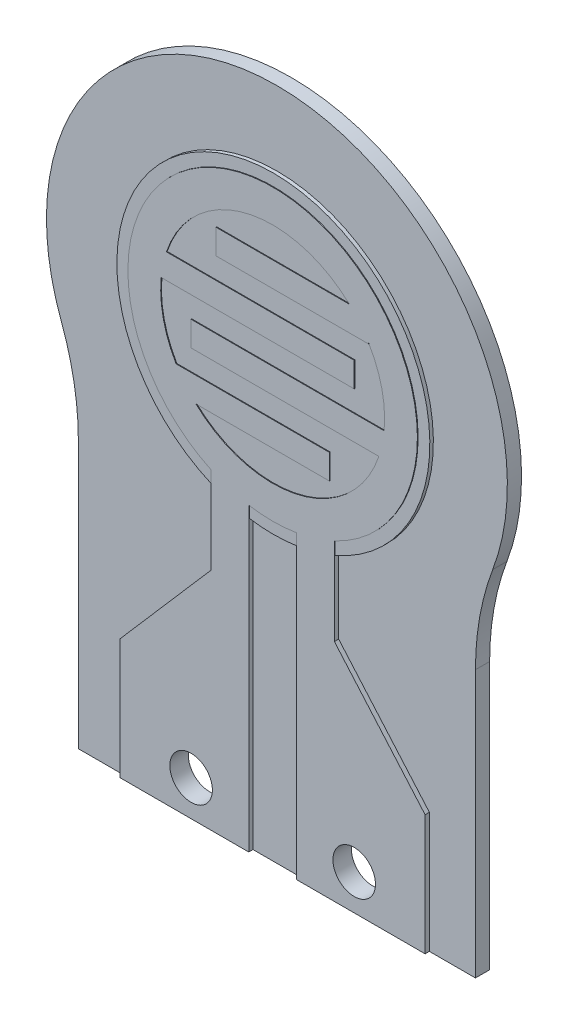
from build123d import *

# Parameters (mm, degrees)
BOSS_EXTRUDE1_DEPTH = 0.2
SKETCH2_R           = 2.206807536
BOSS_EXTRUDE2_DEPTH = 0.25
BOSS_EXTRUDE3_DEPTH = 0.06
SKETCH5_R           = 0.3
CUT_EXTRUDE1_DEPTH  = 1.26


with BuildPart() as part:
    # Sketch1 → Boss-Extrude1 (new body)
    with BuildSketch(Plane.XY):
        with BuildLine():
            Line((-2.8, -6.25), (2.8, -6.25))
            Line((2.8, -6.25), (2.8, -2.484625193))
            ThreePointArc((2.8, -2.484625193), (2.861380635, -1.801298833), (3.043557337, -1.139850312))
            ThreePointArc((3.043557337, -1.139850312), (0, 3.25), (-3.043557337, -1.139850312))
            ThreePointArc((-3.043557337, -1.139850312), (-2.861380635, -1.801298833), (-2.8, -2.484625193))
            Line((-2.8, -2.484625193), (-2.8, -6.25))
        make_face()
    extrude(amount=BOSS_EXTRUDE1_DEPTH)

    # Sketch2 → Boss-Extrude2 (add)
    with BuildSketch(Plane(origin=(0, 0, 0), x_dir=(-1, 0, 0), z_dir=(0, 0, -1))):
        Circle(SKETCH2_R)
    extrude(amount=-BOSS_EXTRUDE2_DEPTH)

    # Sketch3 → Boss-Extrude3 (add)
    with BuildSketch(Plane.XY.offset(0.2)):
        with BuildLine():
            Line((0.870696458, -1.846445486), (0.870696458, -3.07534158))
            Line((0.870696458, -3.07534158), (2.15, -4.550780247))
            Line((2.15, -4.550780247), (2.15, -6.25))
            Line((2.15, -6.25), (0.337052097, -6.25))
            Line((0.337052097, -6.25), (0.337052097, -2.013422245))
            ThreePointArc((0.337052097, -2.013422245), (0, -2.041439016), (-0.337052097, -2.013422245))
            Line((-0.337052097, -2.013422245), (-0.337052097, -6.25))
            Line((-0.337052097, -6.25), (-2.15, -6.25))
            Line((-2.15, -6.25), (-2.15, -4.550780247))
            Line((-2.15, -4.550780247), (-0.870696458, -3.07534158))
            Line((-0.870696458, -3.07534158), (-0.870696458, -1.846445486))
            ThreePointArc((-0.870696458, -1.846445486), (0, 2.041439016), (0.870696458, -1.846445486))
        make_face()
        with BuildLine():
            Line((-0.8, 1.15), (1.081903016, 1.15))
            ThreePointArc((1.081903016, 1.15), (-0.385798466, 1.531069456), (-1.497669568, 0.5))
            Line((-1.497669568, 0.5), (1.15, 0.5))
            Line((1.15, 0.5), (1.15, 0.15))
            Line((1.15, 0.15), (-1.571786925, 0.15))
            ThreePointArc((-1.571786925, 0.15), (-1.54152787, -0.341622545), (-1.361254618, -0.8))
            Line((-1.361254618, -0.8), (0.8, -0.8))
            Line((0.8, -0.8), (0.8, -1.15))
            Line((0.8, -1.15), (-1.081903016, -1.15))
            ThreePointArc((-1.081903016, -1.15), (0.385798466, -1.531069456), (1.497669568, -0.5))
            Line((1.497669568, -0.5), (-1.15, -0.5))
            Line((-1.15, -0.5), (-1.15, -0.15))
            Line((-1.15, -0.15), (1.571786925, -0.15))
            ThreePointArc((1.571786925, -0.15), (1.540204935, 0.347538335), (1.355071738, 0.810428727))
            Line((1.355071738, 0.810428727), (1.355071738, 0.8))
            Line((1.355071738, 0.8), (-0.8, 0.8))
            Line((-0.8, 0.8), (-0.8, 1.15))
        make_face(mode=Mode.SUBTRACT)
    extrude(amount=BOSS_EXTRUDE3_DEPTH)

    # Sketch5 → Cut-Extrude1 (cut, through all)
    with BuildSketch(Plane.XY.offset(0.26)):
        with Locations((-1.15, -5.75)):
            Circle(SKETCH5_R)
        with Locations((1.15, -5.75)):
            Circle(SKETCH5_R)
    extrude(amount=-CUT_EXTRUDE1_DEPTH, mode=Mode.SUBTRACT)


solid = part.part
